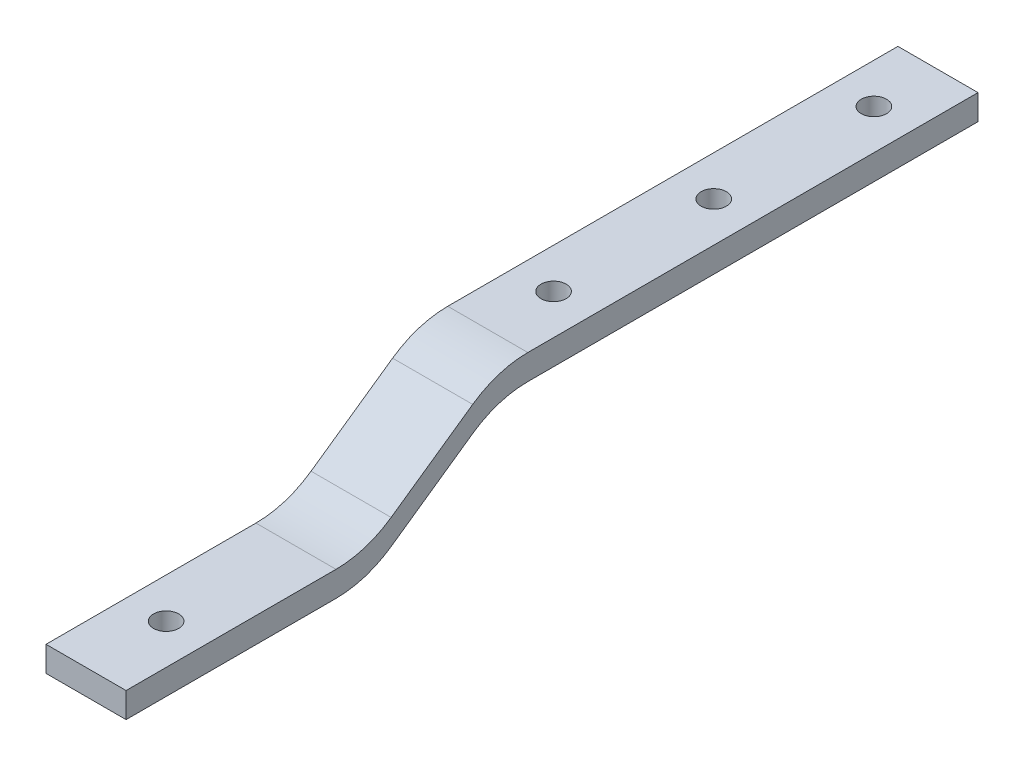
from build123d import *

# Parameters (mm, degrees)
BOSS_EXTRUDE1_DEPTH = 6.35
SKETCH2_R           = 1
CUT_EXTRUDE1_DEPTH  = 2
SKETCH3_R           = 1
CUT_EXTRUDE2_DEPTH  = 2
LPATTERN1_COUNT     = 3
LPATTERN1_PITCH     = 12.7
FILLET1_R           = 7.62


with BuildPart() as part:
    # Sketch1 → Boss-Extrude1 (new body)
    with BuildSketch(Plane(origin=(0, 0, 0), x_dir=(0, 0, -1), z_dir=(1, 0, 0))):
        Polygon((0, 2), (19.05, 2), (29.453230962, 9.284420742), (67.553230962, 9.284420742), (67.553230962, 7.284420742), (29.453230962, 7.284420742), (19.05, 0), (0, 0), align=None)
    extrude(amount=BOSS_EXTRUDE1_DEPTH)

    # Sketch2 → Cut-Extrude1 (cut)
    with BuildSketch(Plane(origin=(0, 2, 0), x_dir=(1, 0, 0), z_dir=(0, 1, 0))):
        with Locations((3.175, 6.35)):
            Circle(SKETCH2_R)
    extrude(amount=-CUT_EXTRUDE1_DEPTH, mode=Mode.SUBTRACT)

    # Sketch3 → Cut-Extrude2 (cut)
    with BuildSketch(Plane(origin=(0, 9.284420742, 0), x_dir=(1, 0, 0), z_dir=(0, 1, 0))):
        with Locations((3.175, 62.473230962)):
            Circle(SKETCH3_R)
    cut_extrude2 = extrude(amount=-CUT_EXTRUDE2_DEPTH, mode=Mode.SUBTRACT)

    # LPattern1: Cut-Extrude2 ×3
    with Locations(*[(0, 0, i * LPATTERN1_PITCH) for i in range(1, LPATTERN1_COUNT)]):
        add(cut_extrude2, mode=Mode.SUBTRACT)

    # Fillet1
    fillet1_edges = [part.edges().sort_by_distance(p)[0] for p in [
        (3.175, 2, -19.05),
        (3.175, 9.284420742, -29.453230962),
        (3.175, 7.284420742, -29.453230962),
        (3.175, 0, -19.05),
    ]]
    fillet(fillet1_edges, radius=FILLET1_R)


solid = part.part
